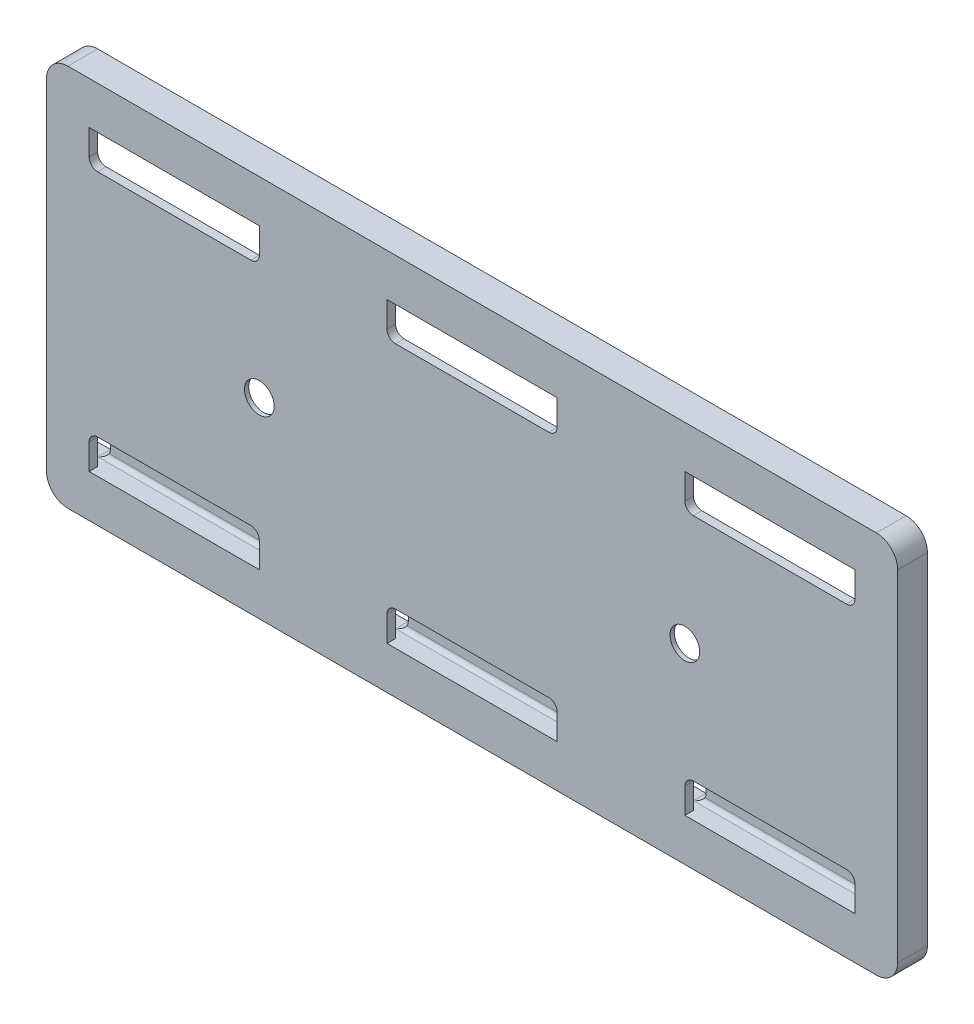
from build123d import *

# Parameters (mm, degrees)
ESBO_O1_W                = 100
ESBO_O1_H                = 45
RESSALTO_EXTRUS_O1_DEPTH = 3.5
ESBO_O2_W                = 97.5
ESBO_O2_H                = 35
CORTE_EXTRUS_O1_DEPTH    = 2.5
RESSALTO_EXTRUS_O2_DEPTH = 1
ESBO_O5_R                = 1.75
CORTE_EXTRUS_O2_DEPTH    = 1.5
CORTE_EXTRUS_O4_DEPTH    = 2.5
ESBO_O7_R                = 3.5
CORTE_EXTRUS_O6_DEPTH    = 0.5
ESBO_O8_W                = 1.200367159
ESBO_O8_H                = 5
ESBO_O8_W_2              = 1
RESSALTO_EXTRUS_O3_DEPTH = 1
FILETE1_R                = 2.5
FILETE2_R                = 2.5
FILETE3_R                = 2.5
FILETE4_R                = 2.5
FILETE5_R                = 0.5
FILETE6_R                = 0.5
FILETE7_R                = 0.5
FILETE8_R                = 0.5
FILETE9_R                = 0.5
FILETE10_R               = 0.5
FILETE11_R               = 1
FILETE12_R               = 1
FILETE13_R               = 1
FILETE14_R               = 1
FILETE15_R               = 1
FILETE16_R               = 1
FILETE17_R               = 1
FILETE18_R               = 0.5
FILETE19_R               = 0.5
FILETE20_R               = 1
FILETE21_R               = 1
FILETE22_R               = 1
FILETE23_R               = 1
FILETE24_R               = 1
FILETE25_R               = 1
FILETE26_R               = 1
FILETE27_R               = 0.5
FILETE28_R               = 0.5
FILETE29_R               = 0.5
FILETE30_R               = 0.5
FILETE31_R               = 0.5
FILETE32_R               = 0.5
CORTE_EXTRUS_O7_DEPTH    = 1
FILETE33_R               = 0.5
FILETE34_R               = 0.5
FILETE35_R               = 0.5
ESBO_O10_W               = 20.001158799
ESBO_O10_H               = 2
ESBO_O10_W_2             = 20
RESSALTO_EXTRUS_O4_DEPTH = 1
FILETE36_R               = 0.5
FILETE37_R               = 0.5
FILETE38_R               = 0.5
FILETE39_R               = 0.5
FILETE40_R               = 0.5
FILETE41_R               = 0.5
CORTE_EXTRUS_O8_DEPTH    = 45.5


with BuildPart() as part:
    # Esboço1 → Ressalto-extrusão1 (new body)
    with BuildSketch(Plane.XY):
        Rectangle(ESBO_O1_W, ESBO_O1_H)
    extrude(amount=RESSALTO_EXTRUS_O1_DEPTH)

    # Esboço2 → Corte-extrusão1 (cut)
    with BuildSketch(Plane(origin=(0, 0, 0), x_dir=(-1, 0, 0), z_dir=(0, 0, -1))):
        with Locations((1.25, 0)):
            Rectangle(ESBO_O2_W, ESBO_O2_H)
    extrude(amount=-CORTE_EXTRUS_O1_DEPTH, mode=Mode.SUBTRACT)

    # Esboço4 → Ressalto-extrusão2 (add)
    with BuildSketch(Plane(origin=(0, 0, 0), x_dir=(-1, 0, 0), z_dir=(0, 0, -1))):
        with BuildLine():
            Line((-45, -22.5), (-25, -22.5))
            Line((-25, -22.5), (-25, -15.5))
            ThreePointArc((-25, -15.5), (-25.292893219, -14.792893219), (-26, -14.5))
            Line((-26, -14.5), (-44, -14.5))
            ThreePointArc((-44, -14.5), (-44.707106781, -14.792893219), (-45, -15.5))
            Line((-45, -15.5), (-45, -22.5))
        make_face()
        with BuildLine():
            Line((-10, -22.5), (10, -22.5))
            Line((10, -22.5), (10, -15.5))
            ThreePointArc((10, -15.5), (9.707106781, -14.792893219), (9, -14.5))
            Line((9, -14.5), (-9, -14.5))
            ThreePointArc((-9, -14.5), (-9.707106781, -14.792893219), (-10, -15.5))
            Line((-10, -15.5), (-10, -22.5))
        make_face()
        with BuildLine():
            Line((25, -22.5), (45, -22.5))
            Line((45, -22.5), (45, -15.5))
            ThreePointArc((45, -15.5), (44.707106781, -14.792893219), (44, -14.5))
            Line((44, -14.5), (26, -14.5))
            ThreePointArc((26, -14.5), (25.292893219, -14.792893219), (25, -15.5))
            Line((25, -15.5), (25, -22.5))
        make_face()
        with BuildLine():
            Line((26, 14.5), (44, 14.5))
            ThreePointArc((44, 14.5), (44.707106781, 14.792893219), (45, 15.5))
            Line((45, 15.5), (45, 22.5))
            Line((45, 22.5), (25, 22.5))
            Line((25, 22.5), (25, 15.5))
            ThreePointArc((25, 15.5), (25.292893219, 14.792893219), (26, 14.5))
        make_face()
        with BuildLine():
            Line((-9, 14.5), (9, 14.5))
            ThreePointArc((9, 14.5), (9.707106781, 14.792893219), (10, 15.5))
            Line((10, 15.5), (10, 22.5))
            Line((10, 22.5), (-10, 22.5))
            Line((-10, 22.5), (-10, 15.5))
            ThreePointArc((-10, 15.5), (-9.707106781, 14.792893219), (-9, 14.5))
        make_face()
        with BuildLine():
            Line((-44, 14.5), (-26, 14.5))
            ThreePointArc((-26, 14.5), (-25.292893219, 14.792893219), (-25, 15.5))
            Line((-25, 15.5), (-25, 22.5))
            Line((-25, 22.5), (-45, 22.5))
            Line((-45, 22.5), (-45, 15.5))
            ThreePointArc((-45, 15.5), (-44.707106781, 14.792893219), (-44, 14.5))
        make_face()
    extrude(amount=-RESSALTO_EXTRUS_O2_DEPTH)

    # Esboço5 → Corte-extrusão2 (cut)
    with BuildSketch(Plane.XY.offset(3.5)):
        with Locations((25, 0)):
            Circle(ESBO_O5_R)
        with Locations((-25, 0)):
            Circle(ESBO_O5_R)
    extrude(amount=-CORTE_EXTRUS_O2_DEPTH, mode=Mode.SUBTRACT)

    # Esboço6 → Corte-extrusão4 (cut)
    with BuildSketch(Plane.XY):
        with BuildLine():
            Line((46.5, -18.5), (23.5, -18.5))
            ThreePointArc((23.5, -18.5), (22.792893219, -18.792893219), (22.5, -19.5))
            Line((22.5, -19.5), (22.5, -20.5))
            ThreePointArc((22.5, -20.5), (22.792893219, -21.207106781), (23.5, -21.5))
            Line((23.5, -21.5), (46.5, -21.5))
            ThreePointArc((46.5, -21.5), (47.207106781, -21.207106781), (47.5, -20.5))
            Line((47.5, -20.5), (47.5, -19.5))
            ThreePointArc((47.5, -19.5), (47.207106781, -18.792893219), (46.5, -18.5))
        make_face()
        with BuildLine():
            Line((20.5, -18.5), (-21.5, -18.5))
            ThreePointArc((-21.5, -18.5), (-22.207106781, -18.792893219), (-22.5, -19.5))
            Line((-22.5, -19.5), (-22.5, -20.5))
            ThreePointArc((-22.5, -20.5), (-22.207106781, -21.207106781), (-21.5, -21.5))
            Line((-21.5, -21.5), (20.5, -21.5))
            ThreePointArc((20.5, -21.5), (21.207106781, -21.207106781), (21.5, -20.5))
            Line((21.5, -20.5), (21.5, -19.5))
            ThreePointArc((21.5, -19.5), (21.207106781, -18.792893219), (20.5, -18.5))
        make_face()
        with BuildLine():
            Line((-24.5, -18.5), (-47.5, -18.5))
            ThreePointArc((-47.5, -18.5), (-48.207106781, -18.792893219), (-48.5, -19.5))
            Line((-48.5, -19.5), (-48.5, -20.5))
            ThreePointArc((-48.5, -20.5), (-48.207106781, -21.207106781), (-47.5, -21.5))
            Line((-47.5, -21.5), (-24.5, -21.5))
            ThreePointArc((-24.5, -21.5), (-23.792893219, -21.207106781), (-23.5, -20.5))
            Line((-23.5, -20.5), (-23.5, -19.5))
            ThreePointArc((-23.5, -19.5), (-23.792893219, -18.792893219), (-24.5, -18.5))
        make_face()
        with BuildLine():
            Line((-24.5, 21.5), (-47.5, 21.5))
            ThreePointArc((-47.5, 21.5), (-48.207106781, 21.207106781), (-48.5, 20.5))
            Line((-48.5, 20.5), (-48.5, 19.5))
            ThreePointArc((-48.5, 19.5), (-48.207106781, 18.792893219), (-47.5, 18.5))
            Line((-47.5, 18.5), (-24.5, 18.5))
            ThreePointArc((-24.5, 18.5), (-23.792893219, 18.792893219), (-23.5, 19.5))
            Line((-23.5, 19.5), (-23.5, 20.5))
            ThreePointArc((-23.5, 20.5), (-23.792893219, 21.207106781), (-24.5, 21.5))
        make_face()
        with BuildLine():
            Line((20.5, 21.5), (-21.5, 21.5))
            ThreePointArc((-21.5, 21.5), (-22.207106781, 21.207106781), (-22.5, 20.5))
            Line((-22.5, 20.5), (-22.5, 19.5))
            ThreePointArc((-22.5, 19.5), (-22.207106781, 18.792893219), (-21.5, 18.5))
            Line((-21.5, 18.5), (20.5, 18.5))
            ThreePointArc((20.5, 18.5), (21.207106781, 18.792893219), (21.5, 19.5))
            Line((21.5, 19.5), (21.5, 20.5))
            ThreePointArc((21.5, 20.5), (21.207106781, 21.207106781), (20.5, 21.5))
        make_face()
        with BuildLine():
            Line((46.5, 21.5), (23.5, 21.5))
            ThreePointArc((23.5, 21.5), (22.792893219, 21.207106781), (22.5, 20.5))
            Line((22.5, 20.5), (22.5, 19.5))
            ThreePointArc((22.5, 19.5), (22.792893219, 18.792893219), (23.5, 18.5))
            Line((23.5, 18.5), (46.5, 18.5))
            ThreePointArc((46.5, 18.5), (47.207106781, 18.792893219), (47.5, 19.5))
            Line((47.5, 19.5), (47.5, 20.5))
            ThreePointArc((47.5, 20.5), (47.207106781, 21.207106781), (46.5, 21.5))
        make_face()
    extrude(amount=CORTE_EXTRUS_O4_DEPTH, mode=Mode.SUBTRACT)

    # Esboço7 → Corte-extrusão6 (cut)
    with BuildSketch(Plane(origin=(0, 0, 2.5), x_dir=(-1, 0, 0), z_dir=(0, 0, -1))):
        with Locations((-25, 0)):
            Circle(ESBO_O7_R)
        with Locations((25, 0)):
            Circle(ESBO_O7_R)
    extrude(amount=-CORTE_EXTRUS_O6_DEPTH, mode=Mode.SUBTRACT)

    # Esboço8 → Ressalto-extrusão3 (add)
    with BuildSketch(Plane(origin=(0, 0, 2.5), x_dir=(-1, 0, 0), z_dir=(0, 0, -1))):
        with Locations((-46.899816421, -10)):
            Rectangle(ESBO_O8_W, ESBO_O8_H)
        with Locations((-47, 0)):
            Rectangle(ESBO_O8_W_2, ESBO_O8_H)
        with Locations((-47, 10)):
            Rectangle(ESBO_O8_W_2, ESBO_O8_H)
    extrude(amount=RESSALTO_EXTRUS_O3_DEPTH)

    # Filete1
    filete1_edges = [part.edges().sort_by_distance(p)[0] for p in [
        (-50, -22.5, 1.75),
    ]]
    fillet(filete1_edges, radius=FILETE1_R)

    # Filete2
    filete2_edges = [part.edges().sort_by_distance(p)[0] for p in [
        (50, -22.5, 1.75),
    ]]
    fillet(filete2_edges, radius=FILETE2_R)

    # Filete3
    filete3_edges = [part.edges().sort_by_distance(p)[0] for p in [
        (50, 22.5, 1.75),
    ]]
    fillet(filete3_edges, radius=FILETE3_R)

    # Filete4
    filete4_edges = [part.edges().sort_by_distance(p)[0] for p in [
        (-50, 22.5, 1.75),
    ]]
    fillet(filete4_edges, radius=FILETE4_R)

    # Filete5
    filete5_edges = [part.edges().sort_by_distance(p)[0] for p in [
        (46.299632841, -12.5, 2),
    ]]
    fillet(filete5_edges, radius=FILETE5_R)

    # Filete6
    filete6_edges = [part.edges().sort_by_distance(p)[0] for p in [
        (46.299632841, -7.5, 2),
    ]]
    fillet(filete6_edges, radius=FILETE6_R)

    # Filete7
    filete7_edges = [part.edges().sort_by_distance(p)[0] for p in [
        (46.5, -2.5, 2),
    ]]
    fillet(filete7_edges, radius=FILETE7_R)

    # Filete8
    filete8_edges = [part.edges().sort_by_distance(p)[0] for p in [
        (46.5, 2.5, 2),
    ]]
    fillet(filete8_edges, radius=FILETE8_R)

    # Filete9
    filete9_edges = [part.edges().sort_by_distance(p)[0] for p in [
        (46.5, 7.5, 2),
    ]]
    fillet(filete9_edges, radius=FILETE9_R)

    # Filete10
    filete10_edges = [part.edges().sort_by_distance(p)[0] for p in [
        (46.5, 12.5, 2),
    ]]
    fillet(filete10_edges, radius=FILETE10_R)

    # Filete11
    filete11_edges = [part.edges().sort_by_distance(p)[0] for p in [
        (45, 17.5, 0.5),
    ]]
    fillet(filete11_edges, radius=FILETE11_R)

    # Filete12
    filete12_edges = [part.edges().sort_by_distance(p)[0] for p in [
        (47.5, 17.5, 1.25),
    ]]
    fillet(filete12_edges, radius=FILETE12_R)

    # Filete13
    filete13_edges = [part.edges().sort_by_distance(p)[0] for p in [
        (25, 17.5, 0.5),
    ]]
    fillet(filete13_edges, radius=FILETE13_R)

    # Filete14
    filete14_edges = [part.edges().sort_by_distance(p)[0] for p in [
        (10, 17.5, 0.5),
    ]]
    fillet(filete14_edges, radius=FILETE14_R)

    # Filete15
    filete15_edges = [part.edges().sort_by_distance(p)[0] for p in [
        (-10, 17.5, 0.5),
    ]]
    fillet(filete15_edges, radius=FILETE15_R)

    # Filete16
    filete16_edges = [part.edges().sort_by_distance(p)[0] for p in [
        (-25, 17.5, 0.5),
    ]]
    fillet(filete16_edges, radius=FILETE16_R)

    # Filete17
    filete17_edges = [part.edges().sort_by_distance(p)[0] for p in [
        (-45, 17.5, 0.5),
    ]]
    fillet(filete17_edges, radius=FILETE17_R)

    # Filete18
    filete18_edges = [part.edges().sort_by_distance(p)[0] for p in [
        (-50, 17.5, 1.25),
    ]]
    fillet(filete18_edges, radius=FILETE18_R)

    # Filete19
    filete19_edges = [part.edges().sort_by_distance(p)[0] for p in [
        (-50, -17.5, 1.25),
    ]]
    fillet(filete19_edges, radius=FILETE19_R)

    # Filete20
    filete20_edges = [part.edges().sort_by_distance(p)[0] for p in [
        (-45, -17.5, 0.5),
    ]]
    fillet(filete20_edges, radius=FILETE20_R)

    # Filete21
    filete21_edges = [part.edges().sort_by_distance(p)[0] for p in [
        (-25, -17.5, 0.5),
    ]]
    fillet(filete21_edges, radius=FILETE21_R)

    # Filete22
    filete22_edges = [part.edges().sort_by_distance(p)[0] for p in [
        (-10, -17.5, 0.5),
    ]]
    fillet(filete22_edges, radius=FILETE22_R)

    # Filete23
    filete23_edges = [part.edges().sort_by_distance(p)[0] for p in [
        (10, -17.5, 0.5),
    ]]
    fillet(filete23_edges, radius=FILETE23_R)

    # Filete24
    filete24_edges = [part.edges().sort_by_distance(p)[0] for p in [
        (25, -17.5, 0.5),
    ]]
    fillet(filete24_edges, radius=FILETE24_R)

    # Filete25
    filete25_edges = [part.edges().sort_by_distance(p)[0] for p in [
        (45, -17.5, 0.5),
    ]]
    fillet(filete25_edges, radius=FILETE25_R)

    # Filete26
    filete26_edges = [part.edges().sort_by_distance(p)[0] for p in [
        (47.5, -17.5, 1.25),
    ]]
    fillet(filete26_edges, radius=FILETE26_R)

    # Filete27
    filete27_edges = [part.edges().sort_by_distance(p)[0] for p in [
        (35, -17.5, 1),
    ]]
    fillet(filete27_edges, radius=FILETE27_R)

    # Filete28
    filete28_edges = [part.edges().sort_by_distance(p)[0] for p in [
        (0, -17.5, 1),
    ]]
    fillet(filete28_edges, radius=FILETE28_R)

    # Filete29
    filete29_edges = [part.edges().sort_by_distance(p)[0] for p in [
        (-35, -17.5, 1),
    ]]
    fillet(filete29_edges, radius=FILETE29_R)

    # Filete30
    filete30_edges = [part.edges().sort_by_distance(p)[0] for p in [
        (-35, 17.5, 1),
    ]]
    fillet(filete30_edges, radius=FILETE30_R)

    # Filete31
    filete31_edges = [part.edges().sort_by_distance(p)[0] for p in [
        (0, 17.5, 1),
    ]]
    fillet(filete31_edges, radius=FILETE31_R)

    # Filete32
    filete32_edges = [part.edges().sort_by_distance(p)[0] for p in [
        (35, 17.5, 1),
    ]]
    fillet(filete32_edges, radius=FILETE32_R)

    # Esboço9 → Corte-extrusão7 (cut)
    with BuildSketch(Plane(origin=(0, 0, 2.5), x_dir=(-1, 0, 0), z_dir=(0, 0, -1))):
        with BuildLine():
            Line((-45, 17.5), (-24.998841201, 17.5))
            Line((-24.998841201, 17.5), (-24.998841201, 14.5))
            ThreePointArc((-24.998841201, 14.5), (-25.29173442, 13.792893219), (-25.998841201, 13.5))
            Line((-25.998841201, 13.5), (-44, 13.5))
            ThreePointArc((-44, 13.5), (-44.707106781, 13.792893219), (-45, 14.5))
            Line((-45, 14.5), (-45, 17.5))
        make_face()
        with BuildLine():
            Line((-10, 17.5), (10, 17.5))
            Line((10, 17.5), (10, 14.5))
            ThreePointArc((10, 14.5), (9.707106781, 13.792893219), (9, 13.5))
            Line((9, 13.5), (-9, 13.5))
            ThreePointArc((-9, 13.5), (-9.707106781, 13.792893219), (-10, 14.5))
            Line((-10, 14.5), (-10, 17.5))
        make_face()
        with BuildLine():
            Line((25, 17.5), (45, 17.5))
            Line((45, 17.5), (45, 14.5))
            ThreePointArc((45, 14.5), (44.707106781, 13.792893219), (44, 13.5))
            Line((44, 13.5), (26, 13.5))
            ThreePointArc((26, 13.5), (25.292893219, 13.792893219), (25, 14.5))
            Line((25, 14.5), (25, 17.5))
        make_face()
        with BuildLine():
            Line((26, -13.5), (44, -13.5))
            ThreePointArc((44, -13.5), (44.707106781, -13.792893219), (45, -14.5))
            Line((45, -14.5), (45, -17.5))
            Line((45, -17.5), (25, -17.5))
            Line((25, -17.5), (25, -14.5))
            ThreePointArc((25, -14.5), (25.292893219, -13.792893219), (26, -13.5))
        make_face()
        with BuildLine():
            Line((-9, -13.5), (9, -13.5))
            ThreePointArc((9, -13.5), (9.707106781, -13.792893219), (10, -14.5))
            Line((10, -14.5), (10, -17.5))
            Line((10, -17.5), (-10, -17.5))
            Line((-10, -17.5), (-10, -14.5))
            ThreePointArc((-10, -14.5), (-9.707106781, -13.792893219), (-9, -13.5))
        make_face()
        with BuildLine():
            Line((-44, -13.5), (-25.998841201, -13.5))
            ThreePointArc((-25.998841201, -13.5), (-25.29173442, -13.792893219), (-24.998841201, -14.5))
            Line((-24.998841201, -14.5), (-24.998841201, -17.5))
            Line((-24.998841201, -17.5), (-45, -17.5))
            Line((-45, -17.5), (-45, -14.5))
            ThreePointArc((-45, -14.5), (-44.707106781, -13.792893219), (-44, -13.5))
        make_face()
    extrude(amount=-CORTE_EXTRUS_O7_DEPTH, mode=Mode.SUBTRACT)

    # Filete33
    filete33_edges = [part.edges().sort_by_distance(p)[0] for p in [
        (47.5, -10, 1.5),
    ]]
    fillet(filete33_edges, radius=FILETE33_R)

    # Filete34
    filete34_edges = [part.edges().sort_by_distance(p)[0] for p in [
        (47.5, 0, 1.5),
    ]]
    fillet(filete34_edges, radius=FILETE34_R)

    # Filete35
    filete35_edges = [part.edges().sort_by_distance(p)[0] for p in [
        (47.5, 10, 1.5),
    ]]
    fillet(filete35_edges, radius=FILETE35_R)

    # Esboço10 → Ressalto-extrusão4 (add)
    with BuildSketch(Plane(origin=(0, 0, 0), x_dir=(-1, 0, 0), z_dir=(0, 0, -1))):
        with Locations((-34.999420601, 15.5)):
            Rectangle(ESBO_O10_W, ESBO_O10_H)
        with Locations((0, 15.5)):
            Rectangle(ESBO_O10_W_2, ESBO_O10_H)
        with Locations((35, 15.5)):
            Rectangle(ESBO_O10_W_2, ESBO_O10_H)
        with Locations((35, -15.5)):
            Rectangle(ESBO_O10_W_2, ESBO_O10_H)
        with Locations((0, -15.5)):
            Rectangle(ESBO_O10_W_2, ESBO_O10_H)
        with Locations((-34.999420601, -15.5)):
            Rectangle(ESBO_O10_W, ESBO_O10_H)
    extrude(amount=-RESSALTO_EXTRUS_O4_DEPTH)

    # Filete36
    filete36_edges = [part.edges().sort_by_distance(p)[0] for p in [
        (-35, 14.5, 1),
    ]]
    fillet(filete36_edges, radius=FILETE36_R)

    # Filete37
    filete37_edges = [part.edges().sort_by_distance(p)[0] for p in [
        (0, 14.5, 1),
    ]]
    fillet(filete37_edges, radius=FILETE37_R)

    # Filete38
    filete38_edges = [part.edges().sort_by_distance(p)[0] for p in [
        (34.9994206, 14.5, 1),
    ]]
    fillet(filete38_edges, radius=FILETE38_R)

    # Filete39
    filete39_edges = [part.edges().sort_by_distance(p)[0] for p in [
        (-35, -14.5, 1),
    ]]
    fillet(filete39_edges, radius=FILETE39_R)

    # Filete40
    filete40_edges = [part.edges().sort_by_distance(p)[0] for p in [
        (0, -14.5, 1),
    ]]
    fillet(filete40_edges, radius=FILETE40_R)

    # Filete41
    filete41_edges = [part.edges().sort_by_distance(p)[0] for p in [
        (34.9994206, -14.5, 1),
    ]]
    fillet(filete41_edges, radius=FILETE41_R)

    # Esboço11 → Corte-extrusão8 (cut, symmetric)
    with BuildSketch(Plane(origin=(0, 0, 0), x_dir=(0, 0, -1), z_dir=(1, 0, 0))):
        with BuildLine():
            Line((0, 15), (-0.5, 15))
            ThreePointArc((-0.5, 15), (-0.853553391, 15.146446609), (-1, 15.5))
            Line((-1, 15.5), (-1, 15.675223152))
            Line((-1, 15.675223152), (-1.230108872, 15.675223152))
            Line((-1.230108872, 15.675223152), (-1.230108872, 15))
            Line((-1.230108872, 15), (-1.230108872, 14.360705072))
            Line((-1.230108872, 14.360705072), (0, 14.360705072))
            Line((0, 14.360705072), (0, 15))
        make_face()
        with BuildLine():
            Line((-1.230108872, -15), (-1.230108872, -15.675223152))
            Line((-1.230108872, -15.675223152), (-1, -15.675223152))
            Line((-1, -15.675223152), (-1, -15.5))
            ThreePointArc((-1, -15.5), (-0.853553391, -15.146446609), (-0.5, -15))
            Line((-0.5, -15), (0, -15))
            Line((0, -15), (0, -14.360705072))
            Line((0, -14.360705072), (-1.230108872, -14.360705072))
            Line((-1.230108872, -14.360705072), (-1.230108872, -15))
        make_face()
    extrude(amount=CORTE_EXTRUS_O8_DEPTH, both=True, mode=Mode.SUBTRACT)


solid = part.part
